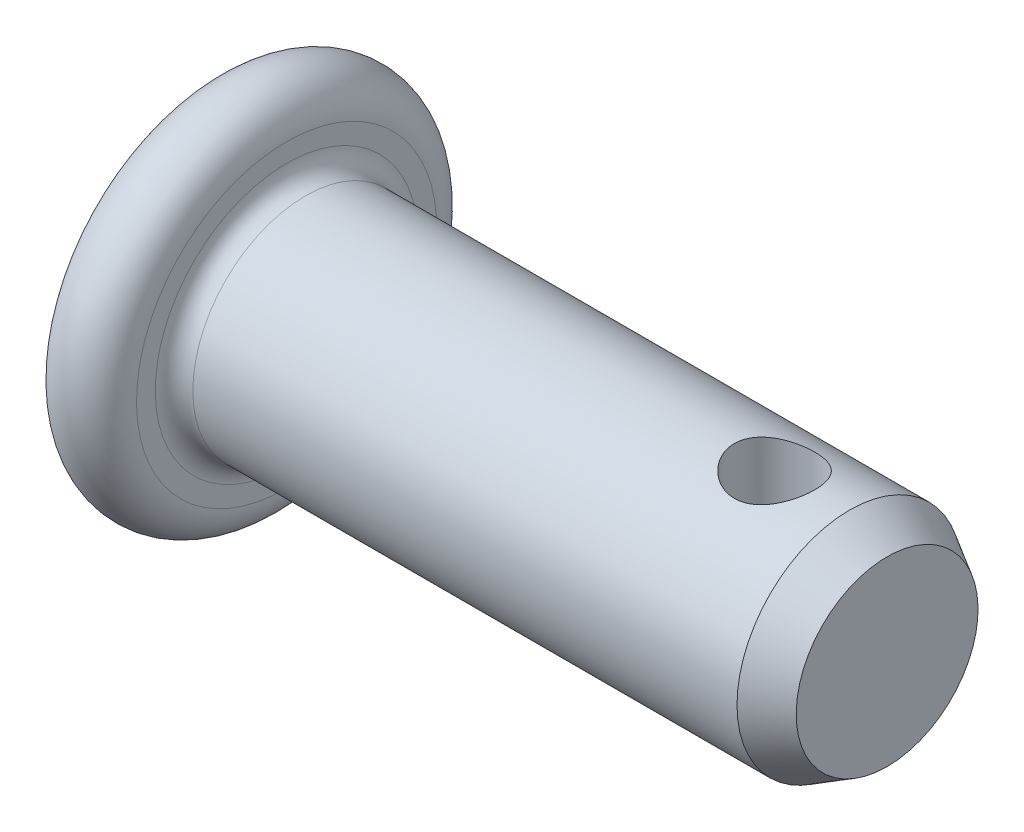
from build123d import *

# Parameters (mm, degrees)
CHAMFER1_R      = 0.5
HOLE_DEPTH      = 20.339079658
HOLE_DEPTH_BACK = 20.339079658
SKETCH2_R       = 1.07


with BuildPart() as part:
    # Sketch1 → BaseBody (revolve)
    with BuildSketch(Plane.XY):
        with BuildLine():
            Line((18, 0), (0, 0))
            Line((0, 0), (0, 4))
            ThreePointArc((0, 4), (1, 5), (2, 4))
            Line((2, 4), (2, 3))
            Line((2, 3), (17, 3))
            Line((17, 3), (18, 2.422649731))
            Line((18, 2.422649731), (18, 0))
        make_face()
    revolve(axis=Axis((-19.830028721, 0, 0), (1, 0, 0)))

    # Chamfer1
    chamfer1_edges = [part.edges().sort_by_distance(p)[0] for p in [
        (2, -3, 0),
    ]]
    fillet(chamfer1_edges, radius=CHAMFER1_R)

    # Sketch2 → Hole (cut, two sides: drawn at the far end of the back side and taken through both)
    with BuildSketch(Plane(origin=(0, 0, 0), x_dir=(1, 0, 0), z_dir=(0, 1, 0)).offset(-HOLE_DEPTH_BACK)):
        with Locations((15, 0)):
            Circle(SKETCH2_R)
    extrude(amount=HOLE_DEPTH + HOLE_DEPTH_BACK, mode=Mode.SUBTRACT)


solid = part.part
